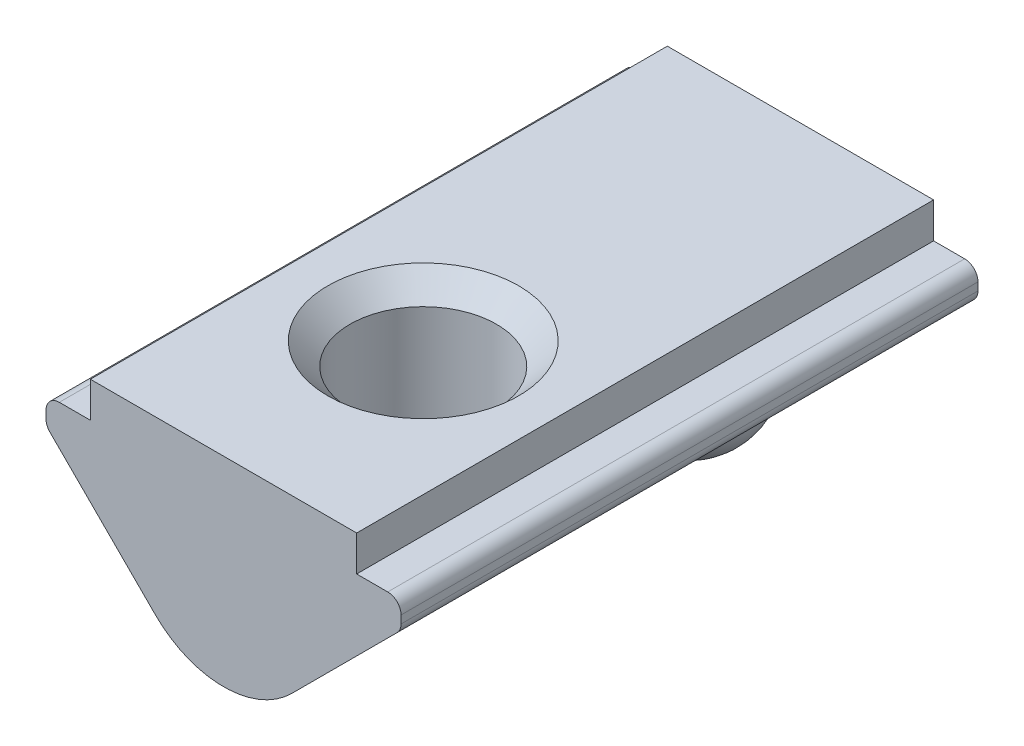
from build123d import *

# Parameters (mm, degrees)
EXTRUDE_1_DEPTH             = 6.5
HOLE_WIZARD_M41_D           = 3.3
HOLE_WIZARD_M41_CSINK_D     = 4.3
HOLE_WIZARD_M41_CSINK_ANGLE = 90
FILLET_1_R                  = 0.3


with BuildPart() as part:
    # Эскиз1 → Бобышка-Вытянуть1 (new body, symmetric)
    with BuildSketch(Plane.XY):
        with BuildLine():
            Line((-3, 0), (3, 0))
            Line((3, 0), (3, -0.8))
            Line((3, -0.8), (4, -0.8))
            Line((4, -0.8), (4, -1.4))
            Line((4, -1.4), (1.536396103, -3.863603897))
            ThreePointArc((1.536396103, -3.863603897), (0, -4.5), (-1.536396103, -3.863603897))
            Line((-1.536396103, -3.863603897), (-4, -1.4))
            Line((-4, -1.4), (-4, -0.8))
            Line((-4, -0.8), (-3, -0.8))
            Line((-3, -0.8), (-3, 0))
        make_face()
    extrude(amount=EXTRUDE_1_DEPTH, both=True)

    # Отверстие обработанное метчиком M41 (through all)
    with Locations(Plane(origin=(0, 0, 0), x_dir=(1, 0, 0), z_dir=(0, 1, 0))):
        with Locations((0, -2)):
            CounterSinkHole(HOLE_WIZARD_M41_D / 2, HOLE_WIZARD_M41_CSINK_D / 2, counter_sink_angle=HOLE_WIZARD_M41_CSINK_ANGLE)

    # Эскиз5 → Повернуть1 (revolve)
    with BuildSketch(Plane(origin=(0, 0, 0), x_dir=(0, 0, -1), z_dir=(1, 0, 0))):
        with BuildLine():
            Line((4, -2), (4, -5))
            ThreePointArc((4, -5), (2.5, -3.5), (4, -2))
        make_face()
    revolve(axis=Axis((0, -2, -4), (0, -1, 0)))

    # Скругление1
    fillet_1_edges = [part.edges().sort_by_distance(p)[0] for p in [
        (4, -0.8, 0),
        (4, -1.4, 0),
        (-4, -1.4, 0),
        (-4, -0.8, 0),
    ]]
    fillet(fillet_1_edges, radius=FILLET_1_R)


solid = part.part
